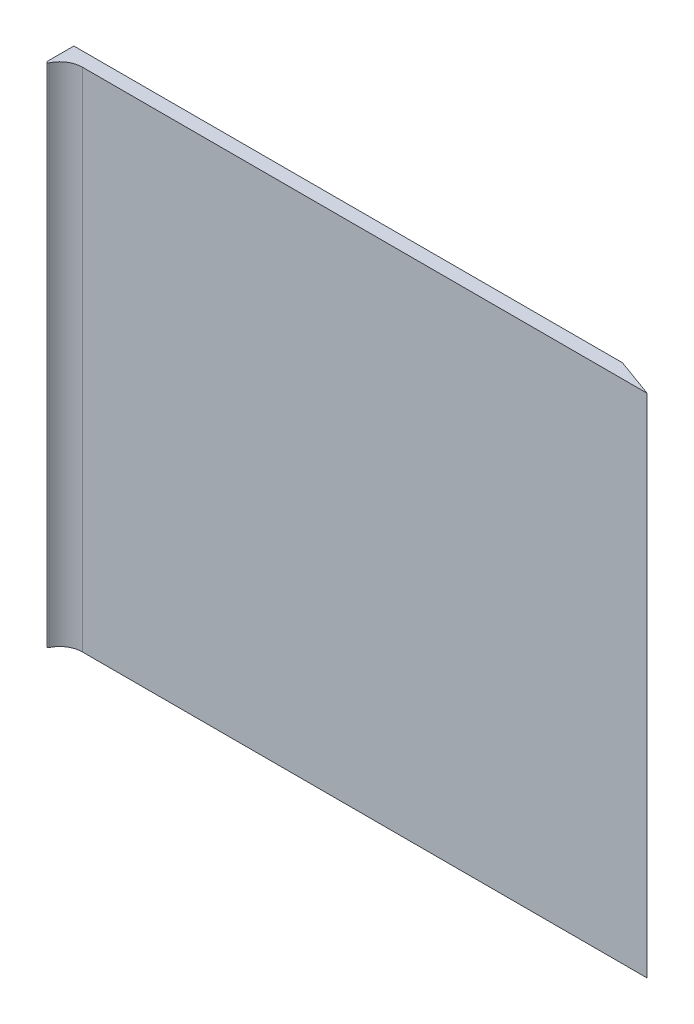
from build123d import *

# Parameters (mm, degrees)
SKETCH1_W           = 195
SKETCH1_H           = 180
BOSS_EXTRUDE1_DEPTH = 2.5
BOSS_EXTRUDE3_DEPTH = 180
BOSS_EXTRUDE4_DEPTH = 180
FILLET1_R           = 0.4


with BuildPart() as part:
    # Sketch1 → Boss-Extrude1 (new body, symmetric)
    with BuildSketch(Plane.XY):
        Rectangle(SKETCH1_W, SKETCH1_H)
    extrude(amount=BOSS_EXTRUDE1_DEPTH, both=True)

    # Sketch4 → Boss-Extrude3 (add)
    with BuildSketch(Plane.XZ.offset(90)):
        with BuildLine():
            Line((-97.5, 2.5), (-97.5, 10.5))
            ThreePointArc((-97.5, 10.5), (-95.156854249, 4.843145751), (-89.5, 2.5))
            Line((-89.5, 2.5), (-97.5, 2.5))
        make_face()
    extrude(amount=-BOSS_EXTRUDE3_DEPTH)

    # Sketch5 → Boss-Extrude4 (add)
    with BuildSketch(Plane.XZ.offset(90)):
        Polygon((97.5, 2.5), (97.5, -2.5), (111.237387097, 2.5), align=None)
    extrude(amount=-BOSS_EXTRUDE4_DEPTH)

    # Fillet1
    fillet1_edges = [part.edges().sort_by_distance(p)[0] for p in [
        (-97.5, 0, 10.5),
    ]]
    fillet(fillet1_edges, radius=FILLET1_R)


solid = part.part
